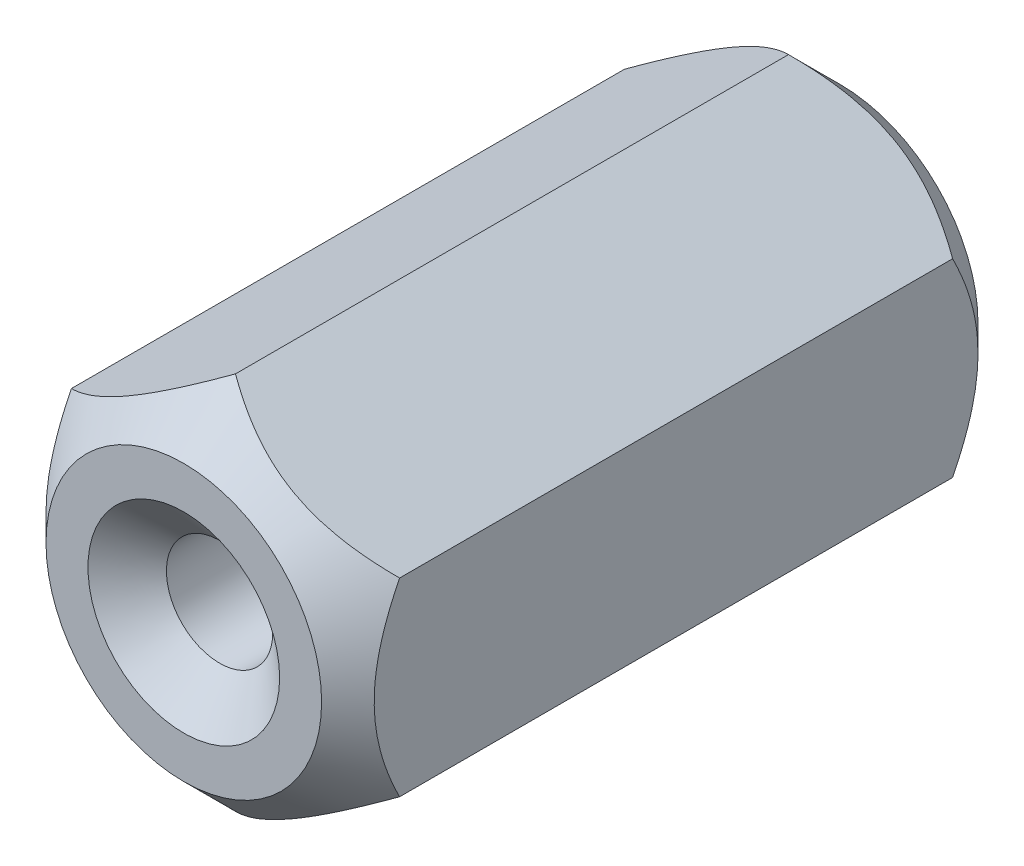
from build123d import *

# Parameters (mm, degrees)
BOSS_EXTRUDE1_DEPTH      = 6.35
BOSS_EXTRUDE1_DEPTH_BACK = 6.35


with BuildPart() as part:
    # Sketch1 → Boss-Extrude1 (new body, two sides)
    with BuildSketch(Plane.XY) as boss_extrude1_sk:
        Polygon((3.175, -1.833087105), (3.175, 1.833087105), (0, 3.666174209), (-3.175, 1.833087105), (-3.175, -1.833087105), (0, -3.666174209), align=None)
    extrude(amount=BOSS_EXTRUDE1_DEPTH)
    extrude(boss_extrude1_sk.sketch, amount=-BOSS_EXTRUDE1_DEPTH_BACK)

    # Sketch3 → Cut-Revolve2 (revolve, cut)
    with BuildSketch(Plane(origin=(0, 0, 0), x_dir=(0, 0, -1), z_dir=(1, 0, 0))):
        Polygon((-5.35, 3.666174209), (-6.35, 2.666174209), (-6.35, 3.666174209), align=None)
    cut_revolve2 = revolve(axis=Axis((0, 0, -0.635), (0, 0, 1)), mode=Mode.SUBTRACT)

    # Mirror1: Cut-Revolve2 across plane
    add(cut_revolve2.mirror(Plane.XY), mode=Mode.SUBTRACT)

    # Sketch4 → CSK for _1 Flat Head Machine Screw _100 (revolve, cut)
    with BuildSketch(Plane(origin=(0, 0, 6.35), x_dir=(0, -1, 0), z_dir=(1, 0, 0))):
        Polygon((0, 0), (0, 12.7), (1.6637, 12.7), (1.0287, 12.065), (1.0287, 0.692676746), (1.8542, 0), align=None)
    revolve(axis=Axis((0, 0, 12.7), (0, 0, -1)), mode=Mode.SUBTRACT)


solid = part.part
